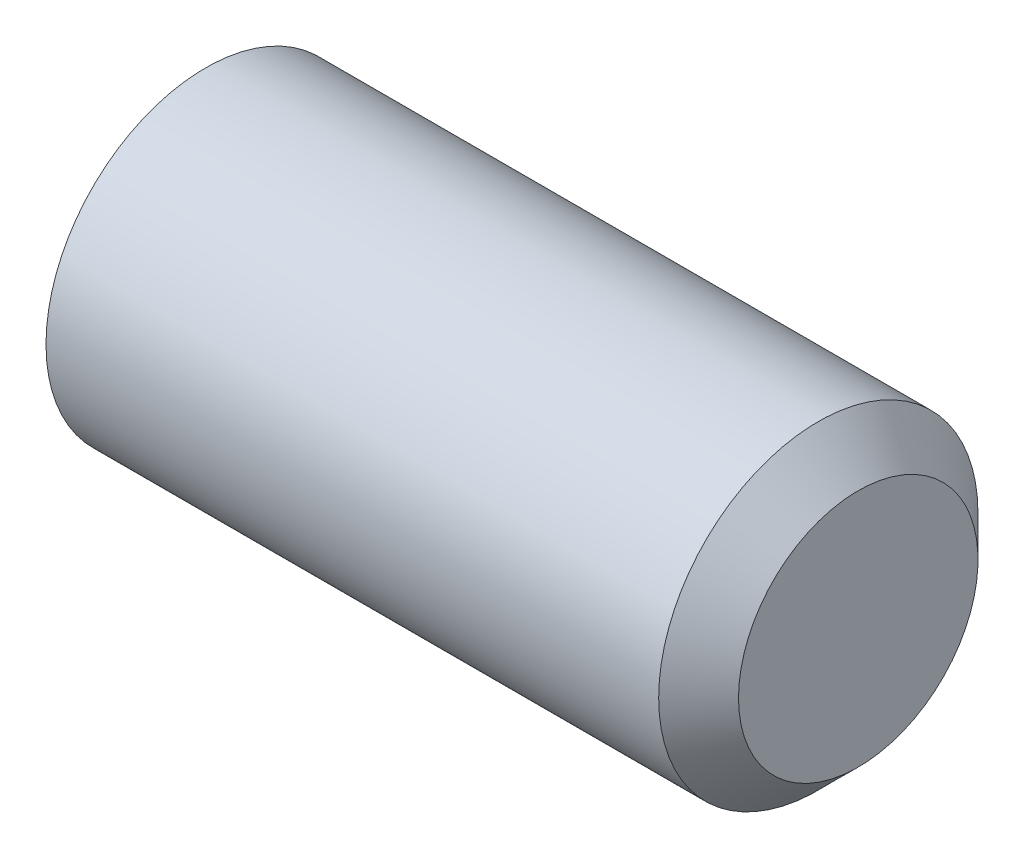
from build123d import *

# Parameters (mm, degrees)
HEX_2_DEPTH = 15


with BuildPart() as part:
    # BodySke → BaseBody (revolve)
    with BuildSketch(Plane.XY):
        Polygon((0, 0), (0, 10.352), (0.951473244, 12), (47, 12), (50, 9), (50, 0), align=None)
    revolve(axis=Axis((-12.7, 0, 0), (1, 0, 0)))

    # Sketch2 → Hex 2 (cut)
    with BuildSketch(Plane.ZY):
        Polygon((3.464101615, 6), (-3.464101615, 6), (-6.92820323, 0), (-3.464101615, -6), (3.464101615, -6), (6.92820323, 0), align=None)
    extrude(amount=-HEX_2_DEPTH, mode=Mode.SUBTRACT)


solid = part.part
